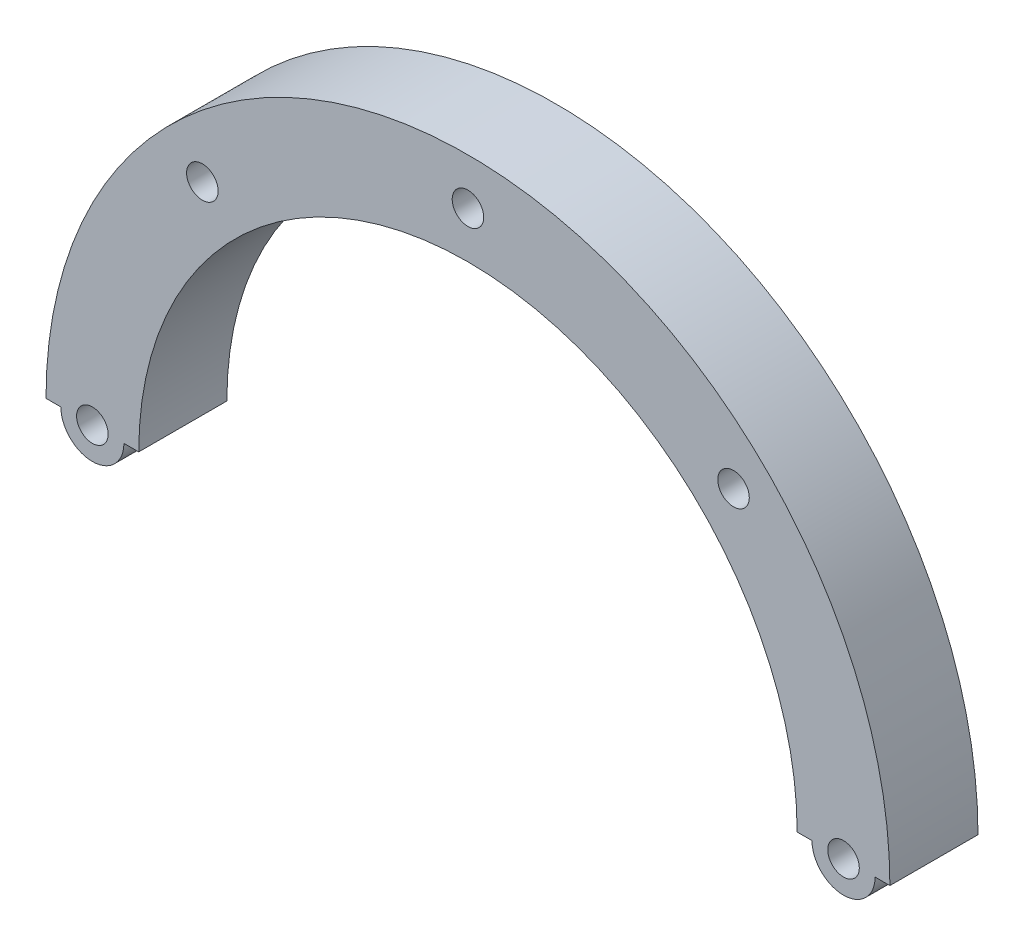
from build123d import *

# Parameters (mm, degrees)
SALIENTE_EXTRUIR1_DEPTH = 9.5
CROQUIS2_R              = 1.7
CORTAR_EXTRUIR1_DEPTH   = 10.5
CROQUIS3_R              = 3.4
CROQUIS3_R_2            = 1.7
SALIENTE_EXTRUIR2_DEPTH = 9.5


with BuildPart() as part:
    # Croquis1 → Saliente-Extruir1 (new body)
    with BuildSketch(Plane.XY):
        with BuildLine():
            Line((-45.5, 0), (-35.5, 0))
            ThreePointArc((-35.5, 0), (0, 35.5), (35.5, 0))
            Line((35.5, 0), (45.5, 0))
            ThreePointArc((45.5, 0), (0, 45.5), (-45.5, 0))
        make_face()
    extrude(amount=SALIENTE_EXTRUIR1_DEPTH)

    # Croquis2 → Cortar-Extruir1 (cut, through all)
    with BuildSketch(Plane.XY.offset(9.5)):
        with Locations((0, 40.5)):
            Circle(CROQUIS2_R)
        with Locations((28.637824638, 28.637824638)):
            Circle(CROQUIS2_R)
        with Locations((40.5, 0)):
            Circle(CROQUIS2_R)
        with Locations((-40.5, 0)):
            Circle(CROQUIS2_R)
        with Locations((-28.637824638, 28.637824638)):
            Circle(CROQUIS2_R)
    extrude(amount=-CORTAR_EXTRUIR1_DEPTH, mode=Mode.SUBTRACT)

    # Croquis3 → Saliente-Extruir2 (add)
    with BuildSketch(Plane.XY.offset(9.5)):
        with Locations((-40.5, 0)):
            Circle(CROQUIS3_R)
        with Locations((-40.5, 0)):
            Circle(CROQUIS3_R_2, mode=Mode.SUBTRACT)
        with Locations((40.5, 0)):
            Circle(CROQUIS3_R)
        with Locations((40.5, 0)):
            Circle(CROQUIS3_R_2, mode=Mode.SUBTRACT)
    extrude(amount=-SALIENTE_EXTRUIR2_DEPTH)


solid = part.part
